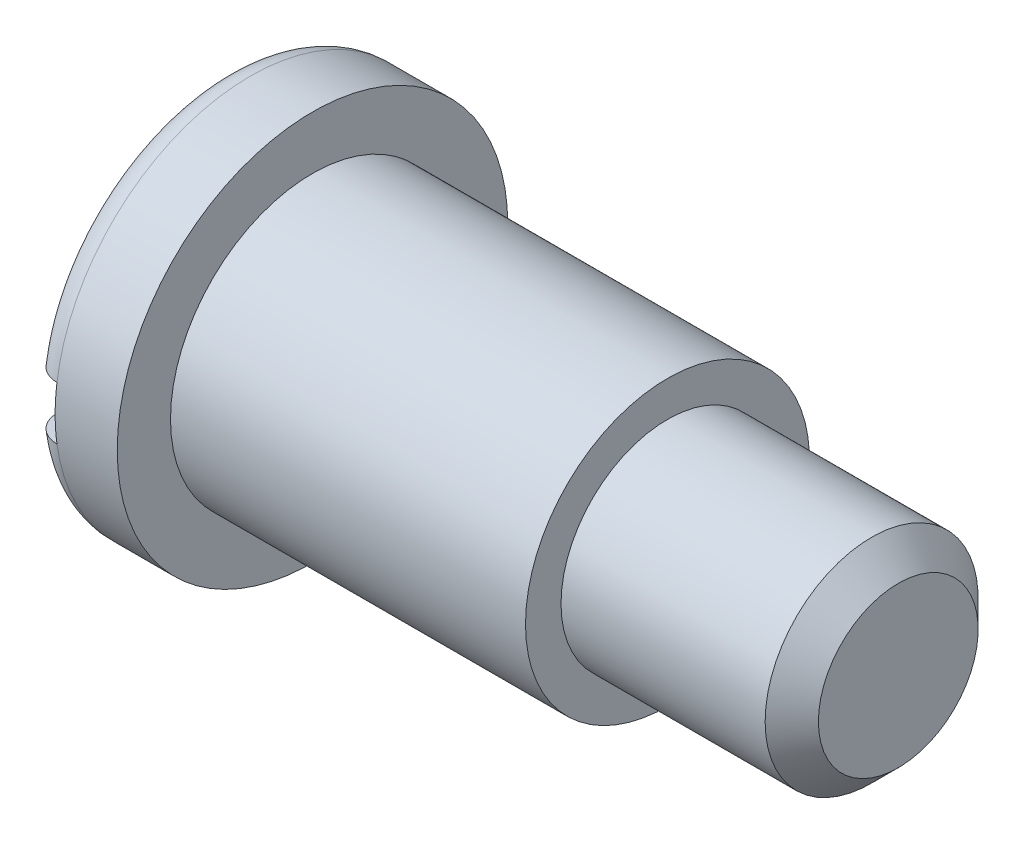
from build123d import *

# Parameters (mm, degrees)
CHAMFER1_SIZE      = 1.5
FILLET1_R          = 1.5
SKETCH3_W          = 23.767877036
SKETCH3_H          = 3
CUT_EXTRUDE1_DEPTH = 1.5


with BuildPart() as part:
    # Sketch1 → Revolve1 (revolve)
    with BuildSketch(Plane.XY):
        Polygon((0, 0), (0, 11), (5, 11), (5, 8), (25, 8), (25, 6), (38, 6), (38, 0), align=None)
    revolve(axis=Axis((-97.318857056, 0, 0), (1, 0, 0)))

    # Chamfer1
    chamfer1_edges = [part.edges().sort_by_distance(p)[0] for p in [
        (38, -6, 0),
    ]]
    chamfer(chamfer1_edges, length=CHAMFER1_SIZE)

    # Fillet1
    fillet1_edges = [part.edges().sort_by_distance(p)[0] for p in [
        (0, -11, 0),
    ]]
    fillet(fillet1_edges, radius=FILLET1_R)

    # Sketch3 → Cut-Extrude1 (cut)
    with BuildSketch(Plane.ZY):
        Rectangle(SKETCH3_W, SKETCH3_H)
    extrude(amount=-CUT_EXTRUDE1_DEPTH, mode=Mode.SUBTRACT)


solid = part.part
